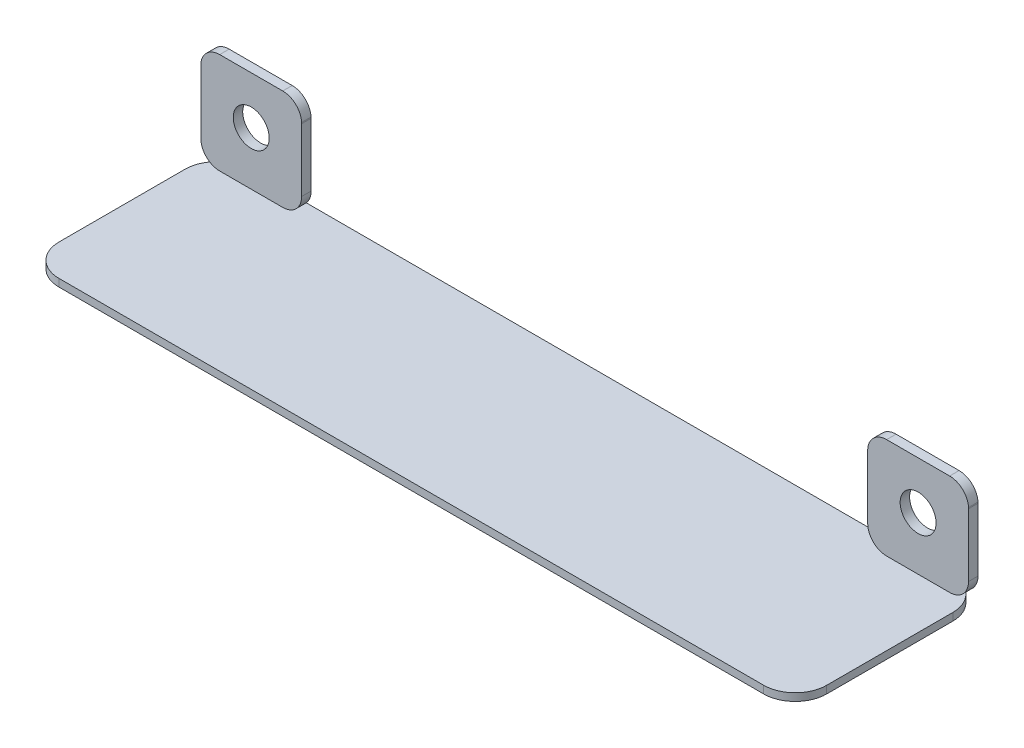
from build123d import *

# Parameters (mm, degrees)
SKETCH3_R             = 2.85
BOSS_EXTRUDE3_DEPTH   = 1.5
BOSS_EXTRUDE3_2_DEPTH = 1.5
SKETCH2_W             = 121.8
SKETCH2_H             = 30
BOSS_EXTRUDE2_DEPTH   = 1.2
FILLET1_R             = 5


with BuildPart() as part:
    # Sketch3 → Boss-Extrude3 (new body)
    with BuildSketch(Plane.XY):
        with BuildLine():
            Line((-7.997540574, -43.228135601), (-8, -43.4))
            Line((-8, -43.4), (-8, -53.4))
            ThreePointArc((-8, -53.4), (-7.121320344, -55.521320344), (-5, -56.4))
            Line((-5, -56.4), (5, -56.4))
            ThreePointArc((5, -56.4), (7.121320344, -55.521320344), (8, -53.4))
            Line((8, -53.4), (8, -43.4))
            Line((8, -43.4), (7.997540574, -43.228135601))
            ThreePointArc((7.997540574, -43.228135601), (7.060914023, -41.218251724), (5, -40.4))
            Line((5, -40.4), (-5, -40.4))
            ThreePointArc((-5, -40.4), (-7.060914023, -41.218251724), (-7.997540574, -43.228135601))
        make_face()
        with Locations((0, -47.952381154)):
            Circle(SKETCH3_R, mode=Mode.SUBTRACT)
    extrude(amount=BOSS_EXTRUDE3_DEPTH)



with BuildPart() as body_2:
    # Sketch3 → Boss-Extrude3 2 (new body)
    with BuildSketch(Plane.XY):
        with BuildLine():
            Line((110.8, -40.4), (100.8, -40.4))
            ThreePointArc((100.8, -40.4), (98.739085977, -41.218251724), (97.802459426, -43.228135601))
            Line((97.802459426, -43.228135601), (97.8, -43.4))
            Line((97.8, -43.4), (97.8, -53.4))
            ThreePointArc((97.8, -53.4), (98.678679656, -55.521320344), (100.8, -56.4))
            Line((100.8, -56.4), (110.8, -56.4))
            ThreePointArc((110.8, -56.4), (112.921320344, -55.521320344), (113.8, -53.4))
            Line((113.8, -53.4), (113.8, -43.4))
            Line((113.8, -43.4), (113.797540574, -43.228135601))
            ThreePointArc((113.797540574, -43.228135601), (112.860914023, -41.218251724), (110.8, -40.4))
        make_face()
        with Locations((105.8, -47.952381154)):
            Circle(SKETCH3_R, mode=Mode.SUBTRACT)
    extrude(amount=BOSS_EXTRUDE3_2_DEPTH)


with BuildPart() as part_1:
    add(part.part)

    add(body_2.part)  # Boss-Extrude2 merges body 2
    # Sketch2 → Boss-Extrude2 (add)
    with BuildSketch(Plane.XZ.offset(56.4)):
        with Locations((52.9, 14)):
            Rectangle(SKETCH2_W, SKETCH2_H)
    extrude(amount=BOSS_EXTRUDE2_DEPTH)

    # Fillet1
    fillet1_edges = [part_1.edges().sort_by_distance(p)[0] for p in [
        (-8, -57, 29),
        (-8, -57, -1),
        (113.8, -57, -1),
        (113.8, -57, 29),
    ]]
    fillet(fillet1_edges, radius=FILLET1_R)


solid = part_1.part
